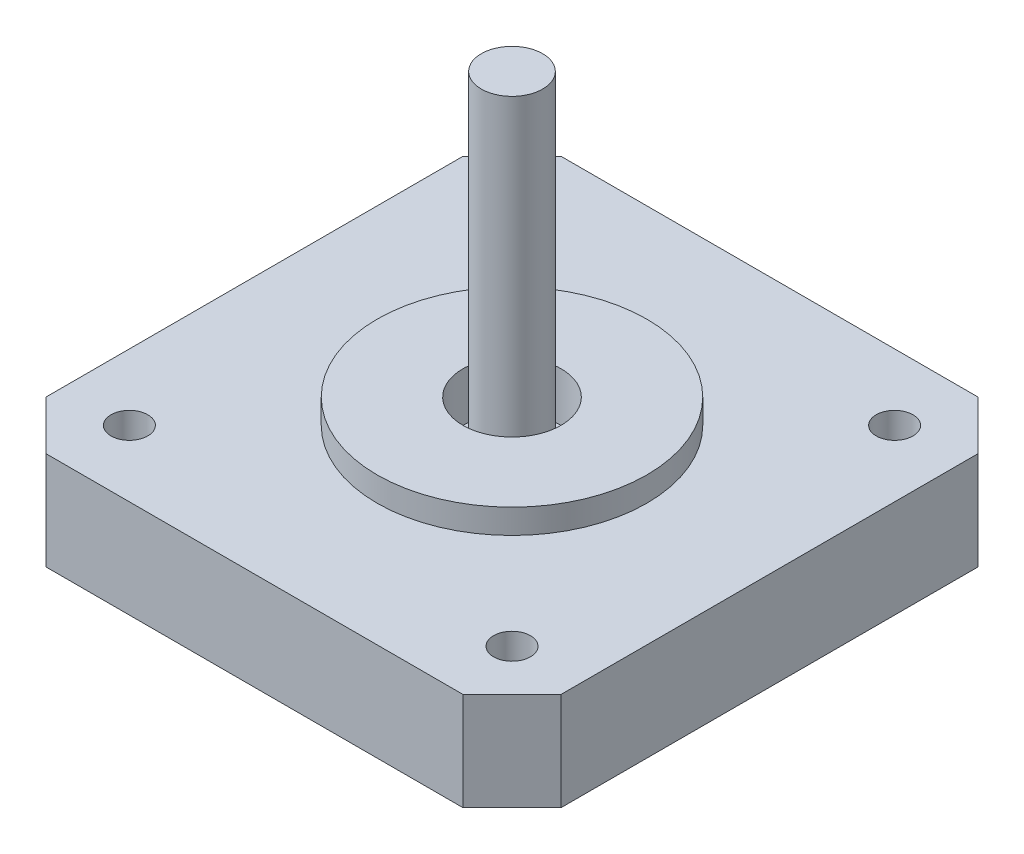
from build123d import *

# Parameters (mm, degrees)
SKETCH1_W               = 42
SKETCH1_H               = 42
BOSS_EXTRUDE1_DEPTH     = 8
SKETCH2_R               = 11
BOSS_EXTRUDE2_DEPTH     = 2
SKETCH3_R               = 4
CUT_EXTRUDE1_DEPTH      = 4
SKETCH4_R               = 2.5
BOSS_EXTRUDE3_DEPTH     = 27
CHAMFER1_SIZE           = 4
SKETCH5_R               = 1.5
CUT_EXTRUDE2_DEPTH      = 26
CUT_EXTRUDE2_DEPTH_BACK = 9


with BuildPart() as part:
    # Sketch1 → Boss-Extrude1 (new body)
    with BuildSketch(Plane(origin=(0, 0, 0), x_dir=(1, 0, 0), z_dir=(0, 1, 0))):
        Rectangle(SKETCH1_W, SKETCH1_H)
    extrude(amount=BOSS_EXTRUDE1_DEPTH)

    # Sketch2 → Boss-Extrude2 (add)
    with BuildSketch(Plane(origin=(0, 8, 0), x_dir=(-1, 0, 0), z_dir=(0, 1, 0))):
        Circle(SKETCH2_R)
    extrude(amount=BOSS_EXTRUDE2_DEPTH)

    # Sketch3 → Cut-Extrude1 (cut)
    with BuildSketch(Plane(origin=(0, 10, 0), x_dir=(1, 0, 0), z_dir=(0, 1, 0))):
        Circle(SKETCH3_R)
    extrude(amount=-CUT_EXTRUDE1_DEPTH, mode=Mode.SUBTRACT)

    # Sketch4 → Boss-Extrude3 (add)
    with BuildSketch(Plane(origin=(0, 6, 0), x_dir=(1, 0, 0), z_dir=(0, 1, 0))):
        Circle(SKETCH4_R)
    extrude(amount=BOSS_EXTRUDE3_DEPTH)

    # Chamfer1
    chamfer1_edges = [part.edges().sort_by_distance(p)[0] for p in [
        (-21, 4, -21),
        (21, 4, -21),
        (21, 4, 21),
        (-21, 4, 21),
    ]]
    chamfer(chamfer1_edges, length=CHAMFER1_SIZE)

    # Sketch5 → Cut-Extrude2 (cut, two sides)
    with BuildSketch(Plane(origin=(0, 8, 0), x_dir=(1, 0, 0), z_dir=(0, 1, 0))) as cut_extrude2_sk:
        with Locations((-15.6, 15.6)):
            Circle(SKETCH5_R)
        with Locations((15.6, 15.6)):
            Circle(SKETCH5_R)
        with Locations((15.6, -15.6)):
            Circle(SKETCH5_R)
        with Locations((-15.6, -15.6)):
            Circle(SKETCH5_R)
    extrude(amount=CUT_EXTRUDE2_DEPTH, mode=Mode.SUBTRACT)
    extrude(cut_extrude2_sk.sketch, amount=-CUT_EXTRUDE2_DEPTH_BACK, mode=Mode.SUBTRACT)


solid = part.part
